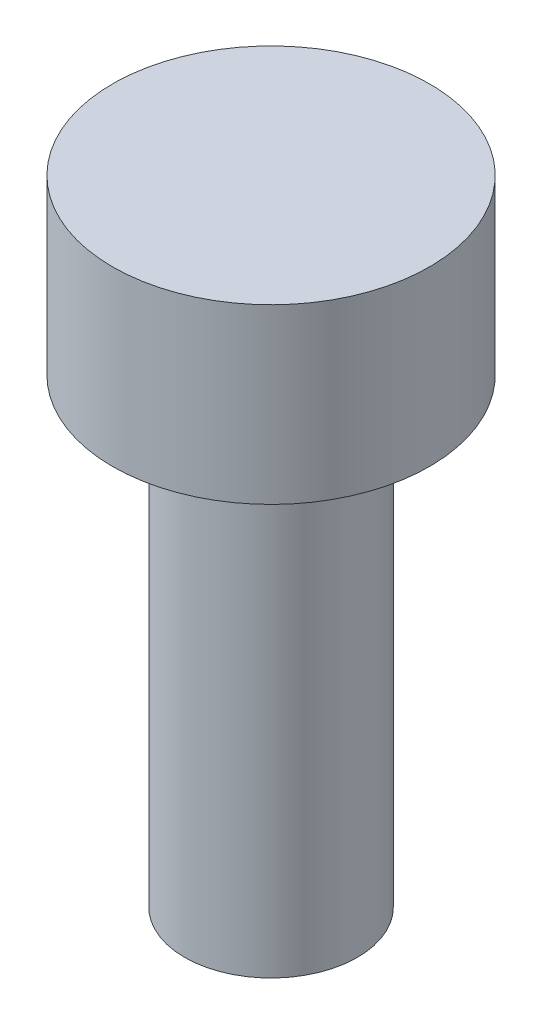
from build123d import *


with BuildPart() as part:
    # profiile → Base-Revolve (revolve)
    with BuildSketch(Plane.XY):
        Polygon((0, 3), (2.75, 3), (2.75, 0), (1.5, 0), (1.5, -8), (0, -8), align=None)
    revolve(axis=Axis((0, 9.907210965, 0), (0, -1, 0)))


solid = part.part
